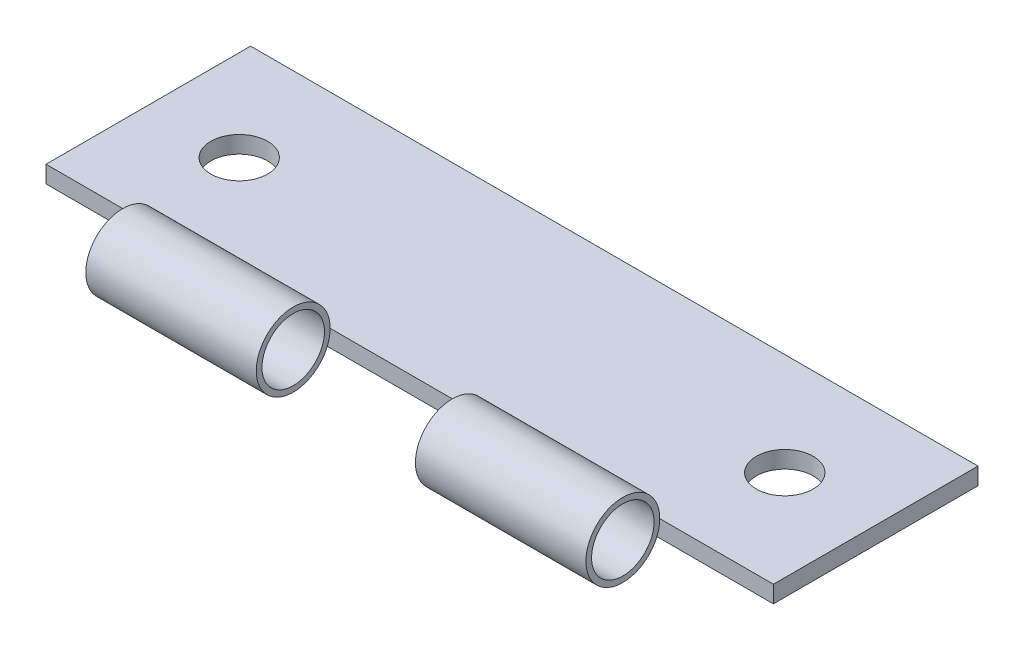
from build123d import *

# Parameters (mm, degrees)
SKETCH1_W               = 64
SKETCH1_H               = 18
BOSS_EXTRUDE1_DEPTH     = 1.5
SKETCH2_R               = 3.25
BOSS_EXTRUDE2_DEPTH     = 32
SKETCH3_R               = 2.5
CUT_EXTRUDE1_DEPTH      = 10
SKETCH4_W               = 10
SKETCH4_H               = 6.5
SKETCH4_W_2             = 14
CUT_EXTRUDE2_DEPTH      = 10
CUT_EXTRUDE2_DEPTH_BACK = 10
SKETCH5_R               = 2.75
CUT_EXTRUDE3_DEPTH      = 44


with BuildPart() as part:
    # Sketch1 → Boss-Extrude1 (new body)
    with BuildSketch(Plane(origin=(0, 0, 0), x_dir=(1, 0, 0), z_dir=(0, 1, 0))):
        Rectangle(SKETCH1_W, SKETCH1_H)
    extrude(amount=BOSS_EXTRUDE1_DEPTH)

    # Sketch3 → Cut-Extrude1 (cut)
    with BuildSketch(Plane(origin=(0, 1.5, 0), x_dir=(1, 0, 0), z_dir=(0, 1, 0))):
        with Locations((-24, 0)):
            Circle(SKETCH3_R)
        with Locations((24, 0)):
            Circle(SKETCH3_R)
    extrude(amount=-CUT_EXTRUDE1_DEPTH, mode=Mode.SUBTRACT)


with BuildPart() as body_2:
    # Sketch2 → Boss-Extrude2 (new body, symmetric)
    with BuildSketch(Plane(origin=(0, 0, 0), x_dir=(0, 0, -1), z_dir=(1, 0, 0))):
        with Locations((-12.25, 1.5)):
            Circle(SKETCH2_R)
    extrude(amount=BOSS_EXTRUDE2_DEPTH, both=True)

    # Sketch4 → Cut-Extrude2 (cut, two sides)
    with BuildSketch(Plane(origin=(0, 0, 0), x_dir=(1, 0, 0), z_dir=(0, 1, 0))) as cut_extrude2_sk:
        with Locations((-27, -12.25)):
            Rectangle(SKETCH4_W, SKETCH4_H)
        with Locations((27, -12.25)):
            Rectangle(SKETCH4_W, SKETCH4_H)
        with Locations((0, -12.25)):
            Rectangle(SKETCH4_W_2, SKETCH4_H)
    extrude(amount=CUT_EXTRUDE2_DEPTH, mode=Mode.SUBTRACT)
    extrude(cut_extrude2_sk.sketch, amount=-CUT_EXTRUDE2_DEPTH_BACK, mode=Mode.SUBTRACT)

    # Sketch5 → Cut-Extrude3 (cut)
    with BuildSketch(Plane(origin=(22, 0, 0), x_dir=(0, 0, -1), z_dir=(1, 0, 0))):
        with Locations((-12.25, 1.5)):
            Circle(SKETCH5_R)
    extrude(amount=-CUT_EXTRUDE3_DEPTH, mode=Mode.SUBTRACT)


solid = Compound([part.part, body_2.part])
